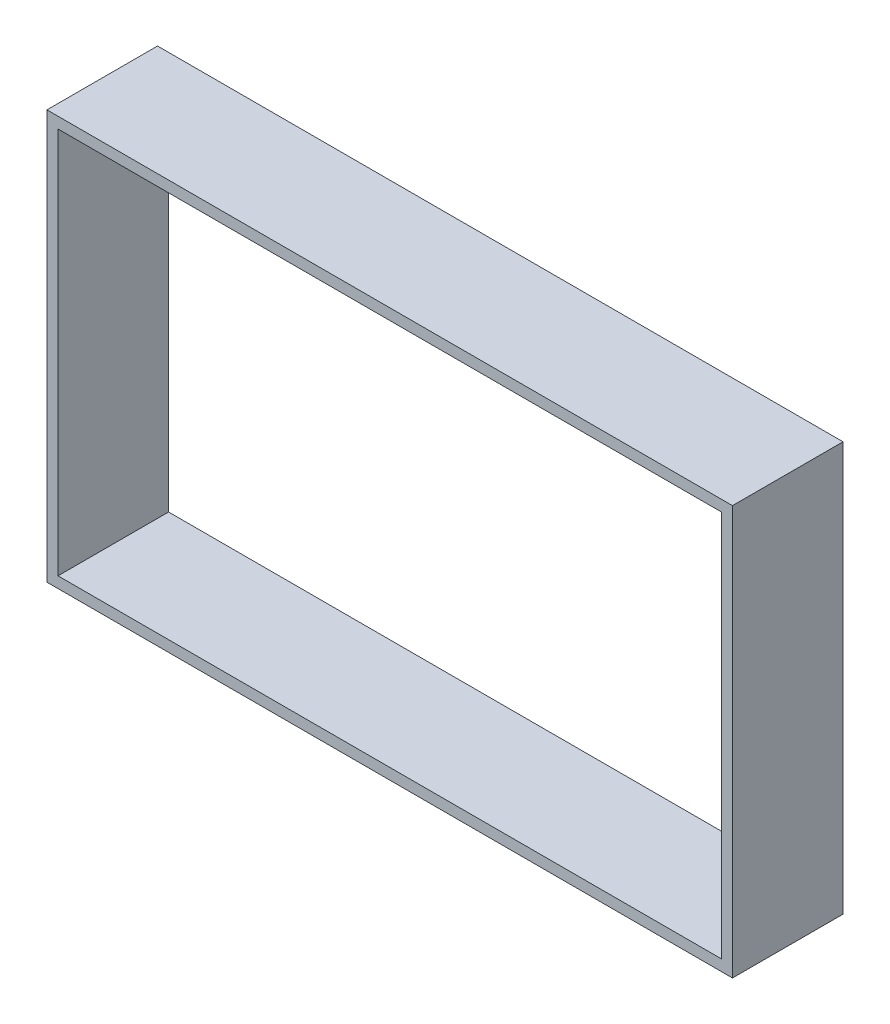
from build123d import *

# Parameters (mm, degrees)
SKETCH1_W           = 62
SKETCH1_H           = 37
SKETCH1_W_2         = 60
SKETCH1_H_2         = 35
EXTRUDE_THIN1_DEPTH = 10


with BuildPart() as part:
    # Sketch1 → Extrude-Thin1 (new body)
    with BuildSketch(Plane.XY):
        Rectangle(SKETCH1_W, SKETCH1_H)
        Rectangle(SKETCH1_W_2, SKETCH1_H_2, mode=Mode.SUBTRACT)
    extrude(amount=EXTRUDE_THIN1_DEPTH)


solid = part.part
